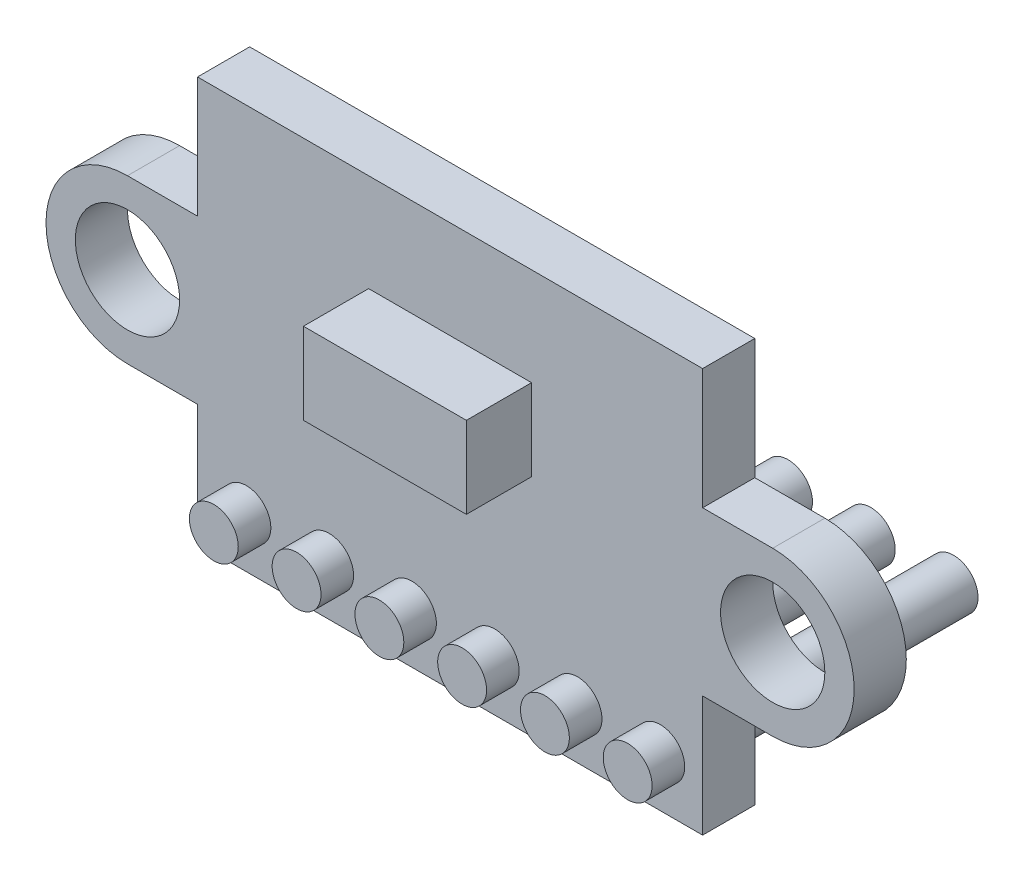
from build123d import *

# Parameters (mm, degrees)
SKETCH1_R       = 1.6
MAIN_DEPTH      = 1.6
SKETCH2_W       = 5
SKETCH2_H       = 2.5
SENSOR_DEPTH    = 2
SKETCH3_R       = 0.75
CABLES_DEPTH    = 10
LPATTERN1_COUNT = 6
LPATTERN1_PITCH = 2.54


with BuildPart() as part:
    # Sketch1 → Main (new body)
    with BuildSketch(Plane.XY):
        with BuildLine():
            Line((-7.75, 6.2), (7.75, 6.2))
            Line((7.75, 6.2), (7.75, 2.5))
            Line((7.75, 2.5), (9.9, 2.5))
            ThreePointArc((9.9, 2.5), (12.4, 0), (9.9, -2.5))
            Line((9.9, -2.5), (7.75, -2.5))
            Line((7.75, -2.5), (7.75, -6.2))
            Line((7.75, -6.2), (-7.75, -6.2))
            Line((-7.75, -6.2), (-7.75, -2.5))
            Line((-7.75, -2.5), (-9.9, -2.5))
            ThreePointArc((-9.9, -2.5), (-12.4, 0), (-9.9, 2.5))
            Line((-9.9, 2.5), (-7.75, 2.5))
            Line((-7.75, 2.5), (-7.75, 6.2))
        make_face()
        with Locations((-9.9, 0)):
            Circle(SKETCH1_R, mode=Mode.SUBTRACT)
        with Locations((9.9, 0)):
            Circle(SKETCH1_R, mode=Mode.SUBTRACT)
    extrude(amount=MAIN_DEPTH)

    # Sketch2 → Sensor (add)
    with BuildSketch(Plane.XY.offset(1.6)):
        with Locations((0, 1.95)):
            Rectangle(SKETCH2_W, SKETCH2_H)
    extrude(amount=SENSOR_DEPTH)

    # Sketch3 → Cables (add)
    with BuildSketch(Plane.XY.offset(2.6)):
        with Locations((-6.25, -4.66)):
            Circle(SKETCH3_R)
    cables = extrude(amount=-CABLES_DEPTH)

    # LPattern1: Cables ×6
    with Locations(*[(i * LPATTERN1_PITCH, 0, 0) for i in range(1, LPATTERN1_COUNT)]):
        add(cables)


solid = part.part
